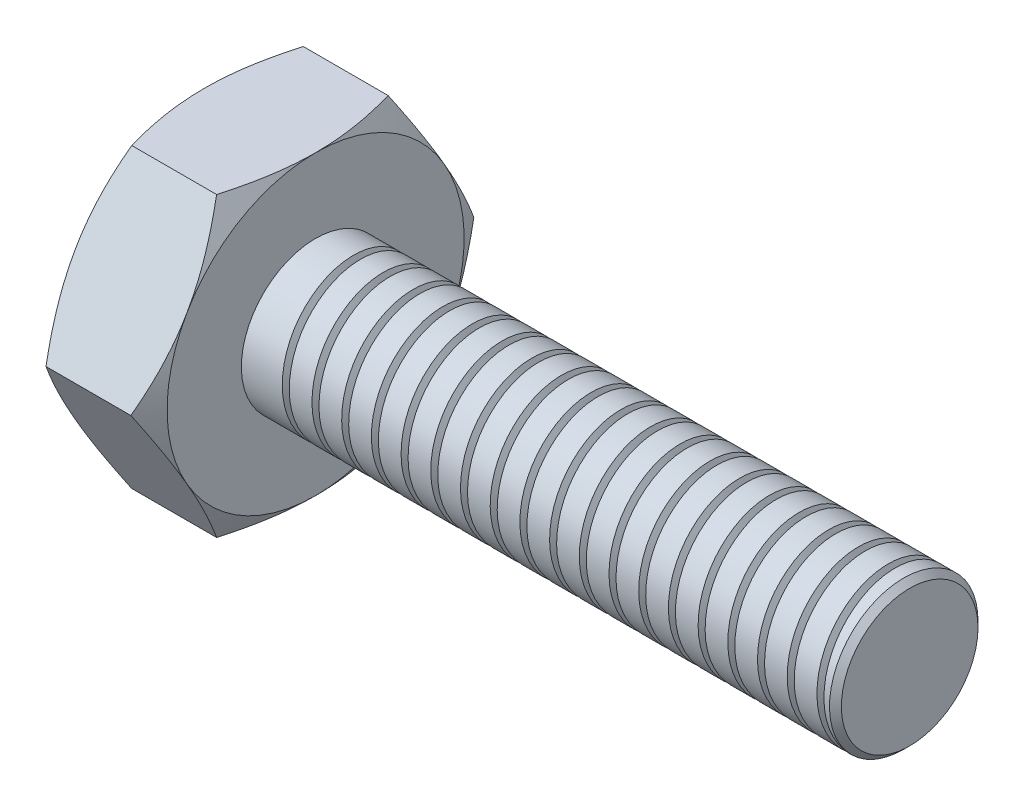
from build123d import *

# Parameters (mm, degrees)
BOSS_EXTRUDE1_DEPTH  = 4.7625
SKETCH2_R            = 3.175
BOSS_EXTRUDE39_DEPTH = 25.4
CUT_SWEEP1_PITCH     = 1.27
CUT_SWEEP1_HEIGHT    = 24.4475
CUT_SWEEP1_RADIUS    = 3.429
SKETCH10_OUTSIDE_W   = 111.824
SKETCH10_OUTSIDE_H   = 109.86
SKETCH10_OUTSIDE_R   = 6.35
CUT_EXTRUDE1_DEPTH   = 25.4
CUT_EXTRUDE1_DRAFT   = -60
SKETCH11_OUTSIDE_W   = 111.824
SKETCH11_OUTSIDE_H   = 109.86
SKETCH11_OUTSIDE_R   = 6.35
CUT_EXTRUDE2_DEPTH   = 25.4
CUT_EXTRUDE2_DRAFT   = -60
SKETCH13_OUTSIDE_W   = 74.636
SKETCH13_OUTSIDE_H   = 72.672
SKETCH13_OUTSIDE_R   = 2.921
CUT_EXTRUDE3_DEPTH   = 25.4
CUT_EXTRUDE3_DRAFT   = -45


with BuildPart() as part:
    # Sketch1 → Boss-Extrude1 (new body)
    with BuildSketch(Plane(origin=(0, 0, 0), x_dir=(0, 0, -1), z_dir=(1, 0, 0))):
        Polygon((-7.332348419, 0), (-3.666174209, -6.35), (3.666174209, -6.35), (7.332348419, 0), (3.666174209, 6.35), (-3.666174209, 6.35), align=None)
    extrude(amount=BOSS_EXTRUDE1_DEPTH)

    # Sketch2 → Boss-Extrude39 (add)
    with BuildSketch(Plane(origin=(4.7625, 0, 0), x_dir=(0, 0, -1), z_dir=(1, 0, 0))):
        Circle(SKETCH2_R)
    extrude(amount=BOSS_EXTRUDE39_DEPTH)

    # Cut-Sweep1: sweep along a helix
    with BuildLine() as cut_sweep1_path:
        Helix(CUT_SWEEP1_PITCH, CUT_SWEEP1_HEIGHT, CUT_SWEEP1_RADIUS, center=(30.1625, 0, 0), direction=(-1, 0, 0))
    # Sketch9 → Cut-Sweep1 (sweep, cut)
    with BuildSketch(Plane(origin=(0, 0, 0), x_dir=(1, 0, 0), z_dir=(0, 1, 0))):
        Polygon((30.607, 3.685632195), (29.718, 3.685632195), (30.1625, 2.915735611), align=None)
    sweep(path=cut_sweep1_path.line, is_frenet=True, mode=Mode.SUBTRACT)


with BuildPart() as cut_extrude1_tool:
    # Sketch10 outside → Cut-Extrude1 (with draft: the straight prism first)
    with BuildSketch(Plane.ZY):
        Rectangle(SKETCH10_OUTSIDE_W, SKETCH10_OUTSIDE_H)
        Circle(SKETCH10_OUTSIDE_R, mode=Mode.SUBTRACT)
    extrude(amount=-CUT_EXTRUDE1_DEPTH)
    # Cut-Extrude1: the draft: its side faces are tilted about the plane it starts from
    cut_extrude1_sides = [cut_extrude1_tool.faces().sort_by_distance(p)[0] for p in [
        (12.7, -54.93, 0),
        (12.7, 0, 55.912),
        (12.7, 54.93, 0),
        (12.7, 0, -55.912),
        (12.7, 0, -6.35),
    ]]
    draft(cut_extrude1_sides, Plane.ZY, CUT_EXTRUDE1_DRAFT)


with BuildPart() as part_1:
    add(part.part)

    # Cut-Extrude1: cut by cut_extrude1_tool
    add(cut_extrude1_tool.part, mode=Mode.SUBTRACT)


with BuildPart() as cut_extrude2_tool:
    # Sketch11 outside → Cut-Extrude2 (with draft: the straight prism first)
    with BuildSketch(Plane(origin=(4.7625, 0, 0), x_dir=(0, 0, -1), z_dir=(1, 0, 0))):
        Rectangle(SKETCH11_OUTSIDE_W, SKETCH11_OUTSIDE_H)
        Circle(SKETCH11_OUTSIDE_R, mode=Mode.SUBTRACT)
    extrude(amount=-CUT_EXTRUDE2_DEPTH)
    # Cut-Extrude2: the draft: its side faces are tilted about the plane it starts from
    cut_extrude2_sides = [cut_extrude2_tool.faces().sort_by_distance(p)[0] for p in [
        (-7.9375, -54.93, 0),
        (-7.9375, 0, -55.912),
        (-7.9375, 54.93, 0),
        (-7.9375, 0, 55.912),
        (-7.9375, 0, 6.35),
    ]]
    draft(cut_extrude2_sides, Plane(origin=(4.7625, 0, 0), x_dir=(0, 0, -1), z_dir=(1, 0, 0)), CUT_EXTRUDE2_DRAFT)


with BuildPart() as part_2:
    add(part_1.part)

    # Cut-Extrude2: cut by cut_extrude2_tool
    add(cut_extrude2_tool.part, mode=Mode.SUBTRACT)


with BuildPart() as cut_extrude3_tool:
    # Sketch13 outside → Cut-Extrude3 (with draft: the straight prism first)
    with BuildSketch(Plane(origin=(30.1625, 0, 0), x_dir=(0, 0, -1), z_dir=(1, 0, 0))):
        Rectangle(SKETCH13_OUTSIDE_W, SKETCH13_OUTSIDE_H)
        Circle(SKETCH13_OUTSIDE_R, mode=Mode.SUBTRACT)
    extrude(amount=-CUT_EXTRUDE3_DEPTH)
    # Cut-Extrude3: the draft: its side faces are tilted about the plane it starts from
    cut_extrude3_sides = [cut_extrude3_tool.faces().sort_by_distance(p)[0] for p in [
        (17.4625, -36.336, 0),
        (17.4625, 0, -37.318),
        (17.4625, 36.336, 0),
        (17.4625, 0, 37.318),
        (17.4625, 0, 2.921),
    ]]
    draft(cut_extrude3_sides, Plane(origin=(30.1625, 0, 0), x_dir=(0, 0, -1), z_dir=(1, 0, 0)), CUT_EXTRUDE3_DRAFT)


with BuildPart() as part_3:
    add(part_2.part)

    # Cut-Extrude3: cut by cut_extrude3_tool
    add(cut_extrude3_tool.part, mode=Mode.SUBTRACT)


solid = part_3.part
